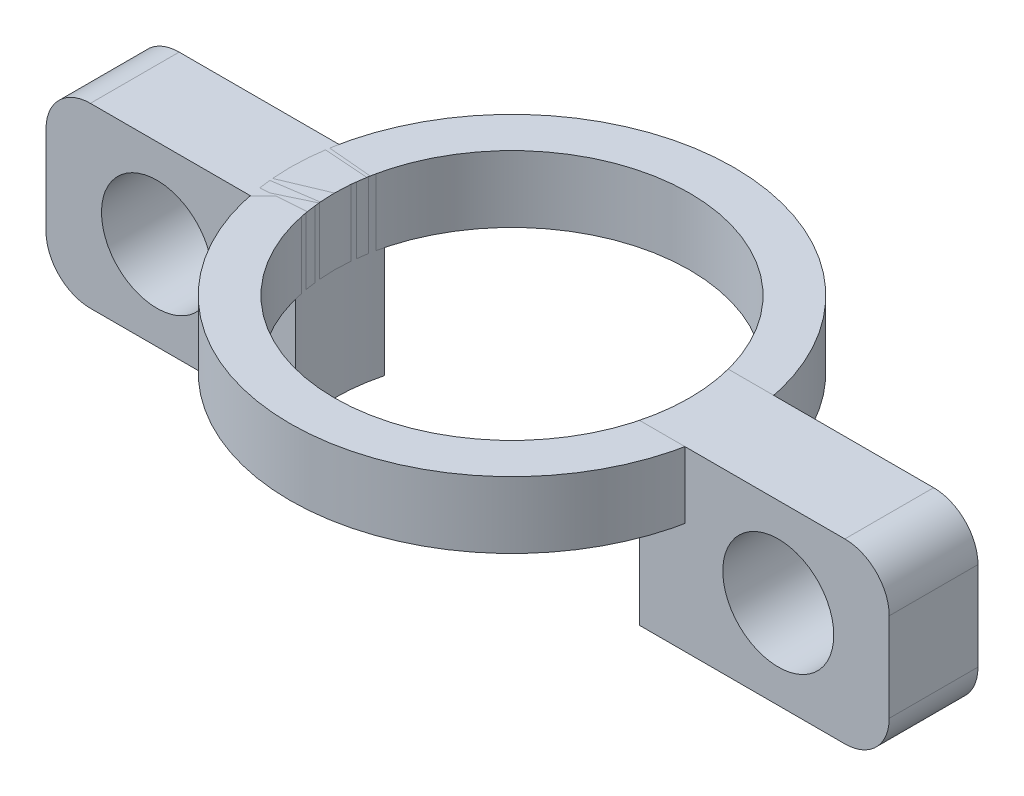
from build123d import *

# Parameters (mm, degrees)
EXTRUDE_1_DEPTH          = 8
SKETCH_2_R               = 2.5
CUT_EXTRUDE_1_DEPTH      = 5
FILLET_1_R               = 2
PATTERN_CIRCULAR_1_COUNT = 2
SKETCH_3_R               = 10
SKETCH_3_R_2             = 8
EXTRUDE_1_2_DEPTH        = 3


with BuildPart() as part:
    # 草图1 → Extrude 1 (new body)
    with BuildSketch(Plane(origin=(0, -55, 0), x_dir=(-1, 0, 0), z_dir=(0, -1, 0))):
        with BuildLine():
            Line((7.745966692, 2), (19, 2))
            Line((19, 2), (19, -2))
            Line((19, -2), (7.745966692, -2))
            ThreePointArc((7.745966692, -2), (8, 0), (7.745966692, 2))
        make_face()
    extrude(amount=-EXTRUDE_1_DEPTH)

    # 草图2 → 切除-拉伸1 (cut, through all)
    with BuildSketch(Plane(origin=(0, 0, -2), x_dir=(-1, 0, 0), z_dir=(0, 0, -1))):
        with Locations((14, -51)):
            Circle(SKETCH_2_R)
    extrude(amount=-CUT_EXTRUDE_1_DEPTH, mode=Mode.SUBTRACT)

    # 圆角1
    fillet_1_edges = [part.edges().sort_by_distance(p)[0] for p in [
        (-19, -47, 0),
        (-19, -55, 0),
    ]]
    fillet(fillet_1_edges, radius=FILLET_1_R)


with BuildPart() as pattern_circular_1_1:
    # 阵列(圆周)1: pattern copy
    add(part.part.rotate(Axis((0, 0, 0), (0, 1, 0)), 1 * 360 / PATTERN_CIRCULAR_1_COUNT))


with BuildPart() as body_3:
    # 草图3 → Extrude 1 2 (new body)
    with BuildSketch(Plane(origin=(0, -47, 0), x_dir=(1, 0, 0), z_dir=(0, 1, 0))):
        Circle(SKETCH_3_R)
        Circle(SKETCH_3_R_2, mode=Mode.SUBTRACT)
    extrude(amount=-EXTRUDE_1_2_DEPTH)


solid = Compound([part.part, pattern_circular_1_1.part, body_3.part])
